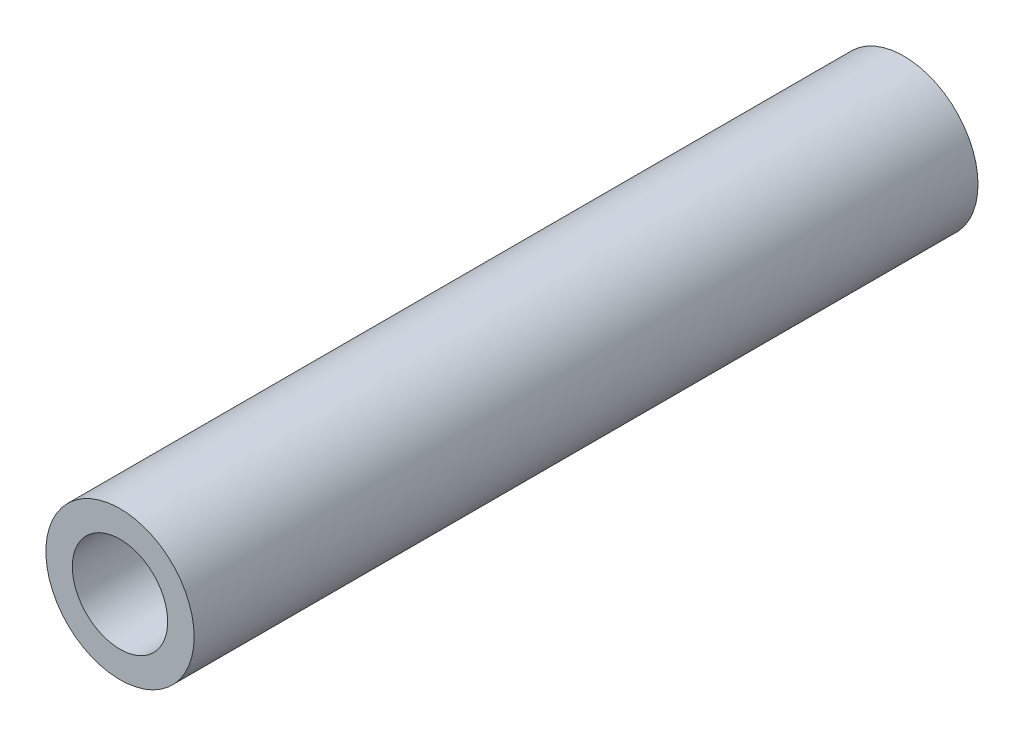
from build123d import *

# Parameters (mm, degrees)
SKETCH1_R            = 3.5
BOSS_EXTRUDE1_DEPTH  = 37
M4_CLEARANCE_HOLE1_D = 4.5


with BuildPart() as part:
    # Sketch1 → Boss-Extrude1 (new body)
    with BuildSketch(Plane.XY):
        Circle(SKETCH1_R)
    extrude(amount=BOSS_EXTRUDE1_DEPTH)

    # M4 Clearance Hole1 (through all)
    with Locations(Plane(origin=(0, 0, 0), x_dir=(-1, 0, 0), z_dir=(0, 0, -1))):
        with Locations((0, 0)):
            Hole(M4_CLEARANCE_HOLE1_D / 2)


solid = part.part
